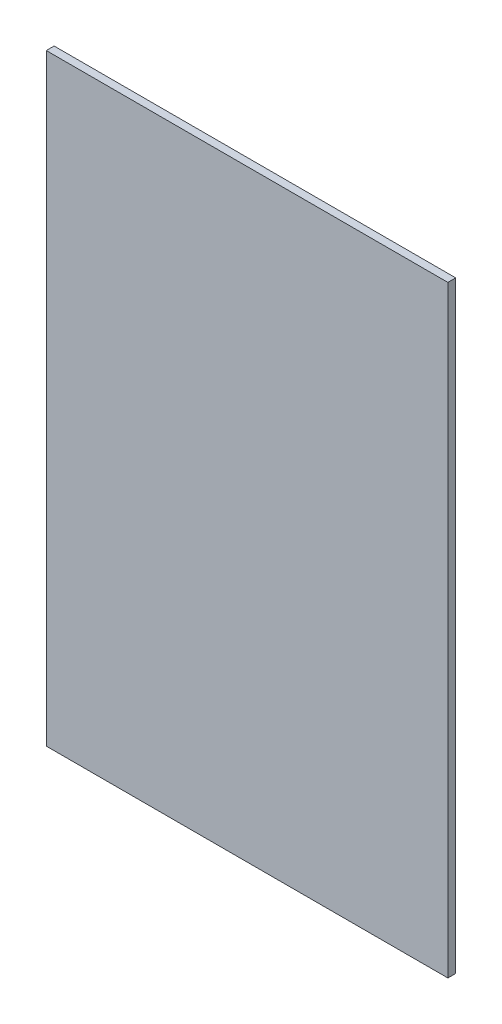
from build123d import *

# Parameters (mm, degrees)
SKETCH1_W           = 609.6
SKETCH1_H           = 914.4
BOSS_EXTRUDE1_DEPTH = 11.90625


with BuildPart() as part:
    # Sketch1 → Boss-Extrude1 (new body)
    with BuildSketch(Plane.XY):
        Rectangle(SKETCH1_W, SKETCH1_H)
    extrude(amount=BOSS_EXTRUDE1_DEPTH)


solid = part.part
